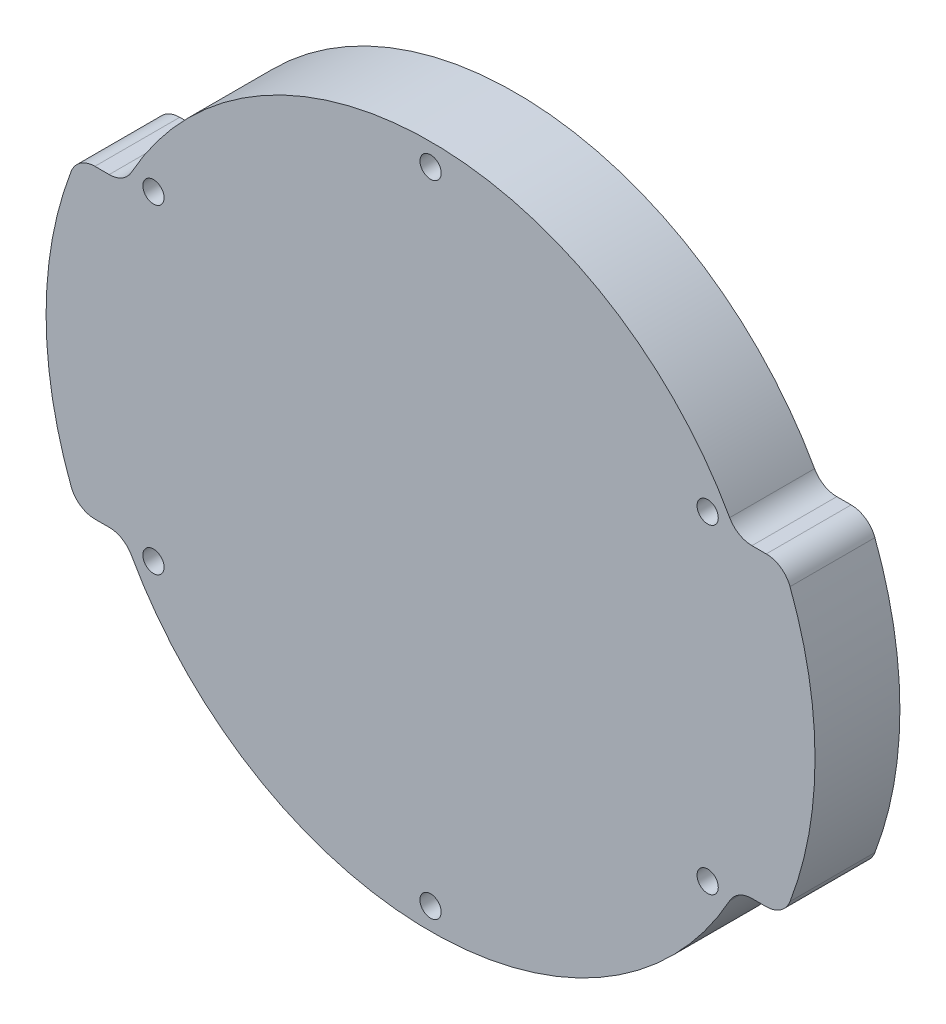
from build123d import *

# Parameters (mm, degrees)
SKETCH_1_R          = 45.3
EXTRUDE_1_DEPTH     = 10
CUT_EXTRUDE_1_DEPTH = 11
FILLET_1_R          = 3
SKETCH_3_R          = 1.25
CUT_EXTRUDE_2_DEPTH = 11


with BuildPart() as part:
    # 草图1 → 凸台-拉伸1 (new body)
    with BuildSketch(Plane.XY):
        Circle(SKETCH_1_R)
    extrude(amount=EXTRUDE_1_DEPTH)

    # 草图2 → 切除-拉伸1 (cut, through all)
    with BuildSketch(Plane.XY.offset(10)):
        with BuildLine():
            Line((-36.056760808, 18), (-41.570301899, 18))
            ThreePointArc((-41.570301899, 18), (0, 45.3), (41.570301899, 18))
            Line((41.570301899, 18), (36.056760808, 18))
            ThreePointArc((36.056760808, 18), (0, 40.3), (-36.056760808, 18))
        make_face()
        with BuildLine():
            Line((-36.056760808, -18), (-41.734622438, -18))
            ThreePointArc((-41.734622438, -18), (0, -45.450838386), (41.734622438, -18))
            Line((41.734622438, -18), (36.056760808, -18))
            ThreePointArc((36.056760808, -18), (0, -40.3), (-36.056760808, -18))
        make_face()
    extrude(amount=-CUT_EXTRUDE_1_DEPTH, mode=Mode.SUBTRACT)

    # 圆角1
    fillet_1_edges = [part.edges().sort_by_distance(p)[0] for p in [
        (36.056760808, 18, 5),
        (-36.056760808, 18, 5),
        (-41.570301899, 18, 5),
        (41.570301899, 18, 5),
        (41.570301899, -18, 5),
        (36.056760808, -18, 5),
        (-41.570301899, -18, 5),
        (-36.056760808, -18, 5),
    ]]
    fillet(fillet_1_edges, radius=FILLET_1_R)

    # 草图3 → 切除-拉伸2 (cut, through all)
    with BuildSketch(Plane.XY.offset(10)):
        with Locations((0, 37.7)):
            Circle(SKETCH_3_R)
        with Locations((32.649157723, 18.85)):
            Circle(SKETCH_3_R)
        with Locations((32.649157723, -18.85)):
            Circle(SKETCH_3_R)
        with Locations((0, -37.7)):
            Circle(SKETCH_3_R)
        with Locations((-32.649157723, -18.85)):
            Circle(SKETCH_3_R)
        with Locations((-32.649157723, 18.85)):
            Circle(SKETCH_3_R)
    extrude(amount=-CUT_EXTRUDE_2_DEPTH, mode=Mode.SUBTRACT)


solid = part.part
